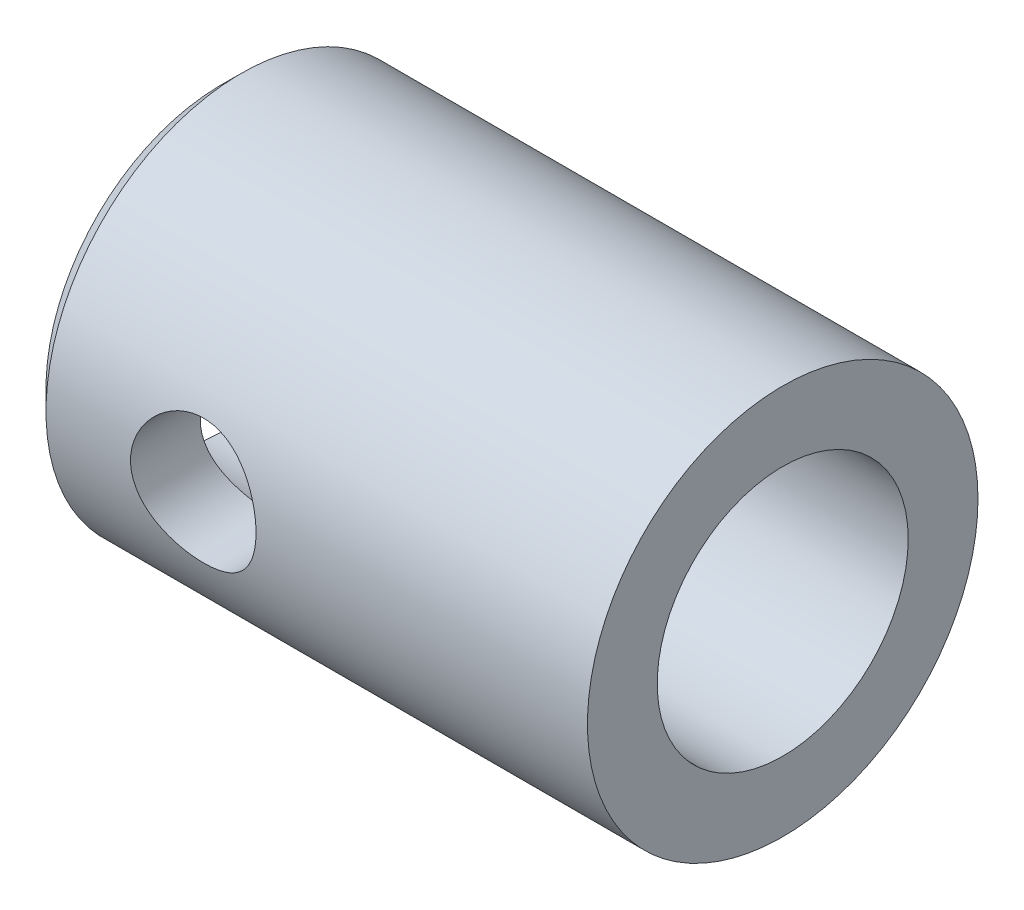
from build123d import *

# Parameters (mm, degrees)
SKETCH1_R           = 14.8209
BOSS_EXTRUDE1_DEPTH = 42.6212
HOLE1_D             = 19.05
HOLE4_D             = 9.525
CHAMFER1_SIZE       = 1.524


with BuildPart() as part:
    # Sketch1 → Boss-Extrude1 (new body)
    with BuildSketch(Plane(origin=(0, 0, 0), x_dir=(0, 0, -1), z_dir=(1, 0, 0))):
        Circle(SKETCH1_R)
    extrude(amount=BOSS_EXTRUDE1_DEPTH)

    # Hole1 (through all)
    with Locations(Plane(origin=(42.6212, 0, 0), x_dir=(0, 0, -1), z_dir=(1, 0, 0))):
        with Locations((0, 0)):
            Hole(HOLE1_D / 2)

    # Hole4 (through all)
    with Locations(Plane(origin=(12.7, 0, 14.8209), x_dir=(1, 0, 0), z_dir=(0, 0, 1))):
        with Locations((0, 0)):
            Hole(HOLE4_D / 2)

    # Chamfer1
    chamfer1_edges = [part.edges().sort_by_distance(p)[0] for p in [
        (0, 0, 14.8209),
    ]]
    chamfer(chamfer1_edges, length=CHAMFER1_SIZE)


solid = part.part
